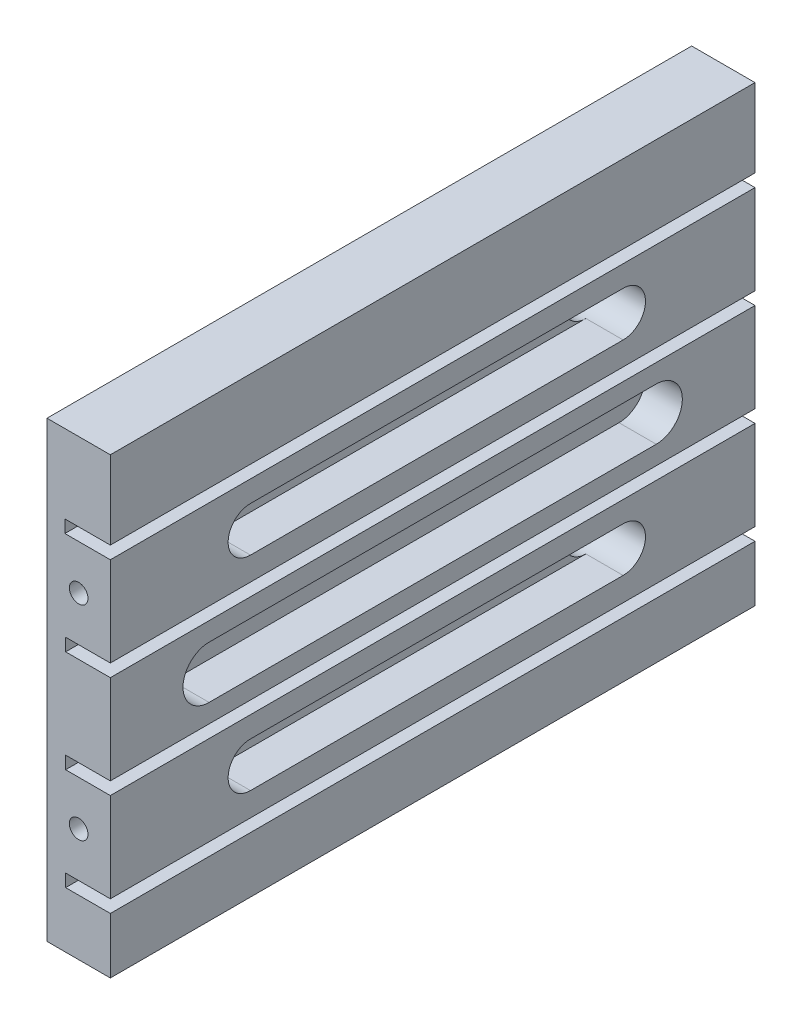
from build123d import *

# Parameters (mm, degrees)
BOSS_EXTRUDE1_DEPTH            = 86.5
M3X0_5_TAPPED_HOLE2_AT_2_COUNT = 2
M3X0_5_TAPPED_HOLE2_AT_2_PITCH = 27.4
M3X0_5_TAPPED_HOLE1_AT_2_COUNT = 2
M3X0_5_TAPPED_HOLE1_AT_2_PITCH = 49
SKETCH14_R                     = 3.5
CUT_EXTRUDE3_DEPTH             = 5
CUT_EXTRUDE1_DEPTH             = 5
SKETCH13_R                     = 3
CUT_EXTRUDE2_DEPTH             = 4.5


with BuildPart() as part:
    # Sketch1 → Boss-Extrude1 (new body)
    with BuildSketch(Plane.XY):
        Polygon((0, 0), (0, 60.8), (8.5, 60.8), (8.5, 50.3), (2.4, 50.3), (2.4, 48.6), (8.5, 48.6), (8.5, 36.6), (2.5, 36.6), (2.5, 34.9), (8.5, 34.9), (8.5, 22.9), (2.5, 22.9), (2.5, 21.2), (8.5, 21.2), (8.5, 9.2), (2.5, 9.2), (2.5, 7.5), (8.5, 7.5), (8.5, 0), align=None)
    extrude(amount=BOSS_EXTRUDE1_DEPTH)

    # Sketch4 → M3x0.5 Tapped Hole2 (revolve, cut)
    with BuildSketch(Plane(origin=(4.25, 42.6, 86.5), x_dir=(0, -1, 0), z_dir=(1, 0, 0))):
        Polygon((0, 0), (0, 6.751075774), (1.25, 6), (1.25, 0), align=None)
    m3x0_5_tapped_hole2 = revolve(axis=Axis((4.25, 42.6, 92.85), (0, 0, -1)), mode=Mode.SUBTRACT)

    # M3x0.5 Tapped Hole2 at 2: M3x0.5 Tapped Hole2 ×2
    with Locations(*[(0, -i * M3X0_5_TAPPED_HOLE2_AT_2_PITCH, 0) for i in range(1, M3X0_5_TAPPED_HOLE2_AT_2_COUNT)]):
        add(m3x0_5_tapped_hole2, mode=Mode.SUBTRACT)

    # Mirror1: M3x0.5 Tapped Hole2 across plane
    add(m3x0_5_tapped_hole2.mirror(Plane.XY.offset(43.25)), mode=Mode.SUBTRACT)

    # Mirror1 copy 1 sketch → Mirror1 copy 1 (revolve, cut)
    with BuildSketch(Plane(origin=(4.25, 15.2, 0), x_dir=(0, -1, 0), z_dir=(1, 0, 0))):
        Polygon((0, 0), (0, -6.751075774), (1.25, -6), (1.25, 0), align=None)
    revolve(axis=Axis((4.25, 15.2, -6.35), (0, 0, -1)), mode=Mode.SUBTRACT)

    # Sketch11 → M3x0.5 Tapped Hole1 (revolve, cut)
    with BuildSketch(Plane(origin=(0, 5, 8.25), x_dir=(0, 0, 1), z_dir=(0, 1, 0))):
        Polygon((0, 0), (0, 4.751075774), (1.25, 4), (1.25, 0), align=None)
    m3x0_5_tapped_hole1 = revolve(axis=Axis((-6.35, 5, 8.25), (1, 0, 0)), mode=Mode.SUBTRACT)

    # M3x0.5 Tapped Hole1 at 2: M3x0.5 Tapped Hole1 ×2
    with Locations(*[(0, i * M3X0_5_TAPPED_HOLE1_AT_2_PITCH, 0) for i in range(1, M3X0_5_TAPPED_HOLE1_AT_2_COUNT)]):
        add(m3x0_5_tapped_hole1, mode=Mode.SUBTRACT)

    # Mirror2: M3x0.5 Tapped Hole1 across plane
    add(m3x0_5_tapped_hole1.mirror(Plane(origin=(0, 0, 43.25), x_dir=(1, 0, 0), z_dir=(0, 0, -1))), mode=Mode.SUBTRACT)

    # Mirror2 copy 1 sketch → Mirror2 copy 1 (revolve, cut)
    with BuildSketch(Plane(origin=(0, 54, 78.25), x_dir=(0, 0, -1), z_dir=(0, 1, 0))):
        Polygon((0, 0), (0, -4.751075774), (1.25, -4), (1.25, 0), align=None)
    revolve(axis=Axis((-6.35, 54, 78.25), (-1, 0, 0)), mode=Mode.SUBTRACT)

    # Sketch14 → Cut-Extrude3 (cut)
    with BuildSketch(Plane(origin=(8.5, 0, 0), x_dir=(0, 0, -1), z_dir=(1, 0, 0))):
        with BuildLine():
            Line((-13.25, 32.4), (-73.25, 32.4))
            ThreePointArc((-73.25, 32.4), (-70.775126266, 31.374873734), (-69.75, 28.9))
            ThreePointArc((-69.75, 28.9), (-70.775126266, 26.425126266), (-73.25, 25.4))
            Line((-73.25, 25.4), (-13.25, 25.4))
            ThreePointArc((-13.25, 25.4), (-16.75, 28.9), (-13.25, 32.4))
        make_face()
        with Locations((-73.25, 28.9)):
            Circle(SKETCH14_R)
        with Locations((-13.25, 28.9)):
            Circle(SKETCH14_R)
    extrude(amount=-CUT_EXTRUDE3_DEPTH, mode=Mode.SUBTRACT)

    # Sketch12 → Cut-Extrude1 (cut)
    with BuildSketch(Plane(origin=(8.5, 0, 0), x_dir=(0, 0, -1), z_dir=(1, 0, 0))):
        with BuildLine():
            Line((-17.695375576, 45.740393433), (-67.695375576, 45.740393433))
            ThreePointArc((-67.695375576, 45.740393433), (-70.695375576, 42.740393433), (-67.695375576, 39.740393433))
            Line((-67.695375576, 39.740393433), (-17.695375576, 39.740393433))
            ThreePointArc((-17.695375576, 39.740393433), (-14.695375576, 42.740393433), (-17.695375576, 45.740393433))
        make_face()
        with BuildLine():
            Line((-17.695375576, 18.378921852), (-67.695375576, 18.378921852))
            ThreePointArc((-67.695375576, 18.378921852), (-70.695375576, 15.378921852), (-67.695375576, 12.378921852))
            Line((-67.695375576, 12.378921852), (-17.695375576, 12.378921852))
            ThreePointArc((-17.695375576, 12.378921852), (-14.695375576, 15.378921852), (-17.695375576, 18.378921852))
        make_face()
    extrude(amount=-CUT_EXTRUDE1_DEPTH, mode=Mode.SUBTRACT)

    # Sketch13 → Cut-Extrude2 (cut, through all)
    with BuildSketch(Plane(origin=(3.5, 0, 0), x_dir=(0, 0, -1), z_dir=(1, 0, 0))):
        with Locations((-67.695375576, 42.740393433)):
            Circle(SKETCH13_R)
        with Locations((-17.695375576, 42.740393433)):
            Circle(SKETCH13_R)
        with Locations((-17.695375576, 15.378921852)):
            Circle(SKETCH13_R)
        with Locations((-67.695375576, 15.378921852)):
            Circle(SKETCH13_R)
    extrude(amount=-CUT_EXTRUDE2_DEPTH, mode=Mode.SUBTRACT)


solid = part.part
